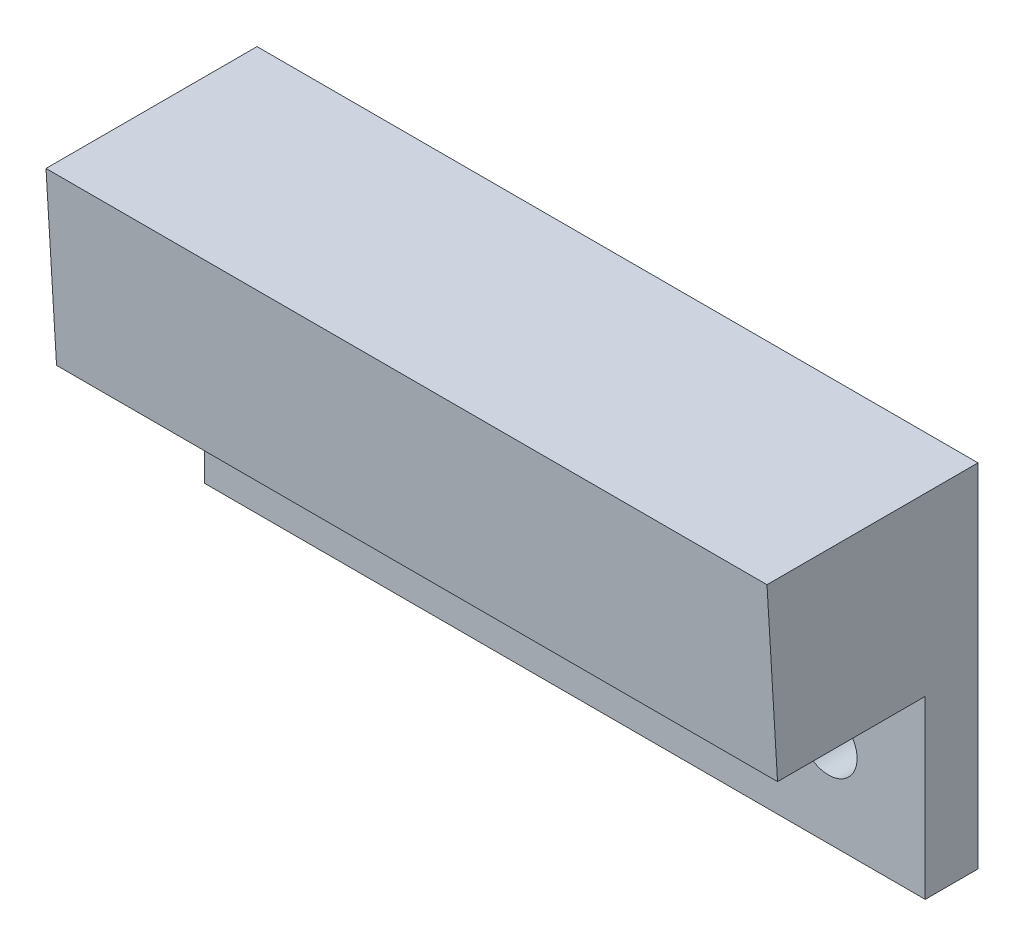
from build123d import *

# Parameters (mm, degrees)
ESQUISSE1_W             = 41
ESQUISSE1_H             = 10
BOSS_EXTRU_1_DEPTH      = 12
ESQUISSE2_W             = 41
ESQUISSE2_H             = 3
BOSS_EXTRU_2_DEPTH      = 10
ESQUISSE3_R             = 1.625
ENL_V_MAT_EXTRU_1_DEPTH = 10
ENL_V_MAT_EXTRU_2_DEPTH = 42


with BuildPart() as part:
    # Esquisse1 → Boss.-Extru.1 (new body)
    with BuildSketch(Plane.XY):
        with Locations((20.5, -5)):
            Rectangle(ESQUISSE1_W, ESQUISSE1_H)
    extrude(amount=BOSS_EXTRU_1_DEPTH)

    # Esquisse2 → Boss.-Extru.2 (add)
    with BuildSketch(Plane.XZ.offset(10)):
        with Locations((20.5, 1.5)):
            Rectangle(ESQUISSE2_W, ESQUISSE2_H)
    extrude(amount=BOSS_EXTRU_2_DEPTH)

    # Esquisse3 → Enlèv. mat.-Extru.1 (cut)
    with BuildSketch(Plane.XY.offset(3)):
        with Locations((5.5, -15)):
            Circle(ESQUISSE3_R)
        with Locations((35.5, -15)):
            Circle(ESQUISSE3_R)
    extrude(amount=-ENL_V_MAT_EXTRU_1_DEPTH, mode=Mode.SUBTRACT)

    # Esquisse4 → Enlèv. mat.-Extru.2 (cut, through all)
    with BuildSketch(Plane(origin=(41, 0, 0), x_dir=(0, 0, -1), z_dir=(1, 0, 0))):
        Polygon((-12, 0), (-11.4, -10), (-12, -10), align=None)
    extrude(amount=-ENL_V_MAT_EXTRU_2_DEPTH, mode=Mode.SUBTRACT)


solid = part.part
